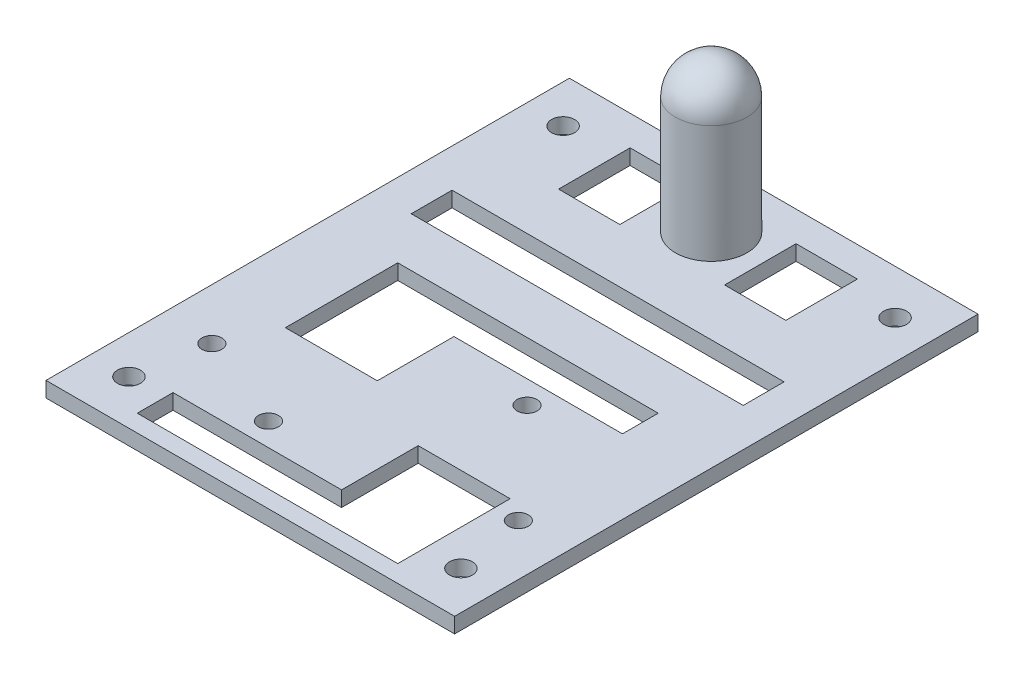
from build123d import *

# Parameters (mm, degrees)
ESQUISSE1_R             = 65
DISQUE_DEPTH            = 3
ESQUISSE3_W             = 30.466369815
ESQUISSE3_H             = 200
COT_S_DEPTH             = 4
D_GAGEMENT_M3_52_D      = 3.9
D_GAGEMENT_M42_D        = 4.5
ESQUISSE15_W            = 89.863216067
ESQUISSE15_H            = 32.096215679
ENL_V_MAT_EXTRU_1_DEPTH = 34
D_GAGEMENT_M3_53_D      = 3.9
D_GAGEMENT_M3_53_DEPTH  = 3
D_GAGEMENT_M3_53_TIP    = 1.171678207
ESQUISSE22_W            = 113.248519978
ESQUISSE22_H            = 34.612898142
ESQUISSE22_W_2          = 51
ESQUISSE22_H_2          = 7
ESQUISSE22_W_3          = 65
ESQUISSE22_H_3          = 8
ENL_V_MAT_EXTRU_3_DEPTH = 10
ESQUISSE23_W            = 12
ESQUISSE23_H            = 14
ENL_V_MAT_EXTRU_4_DEPTH = 10
ESQUISSE24_W            = 18
ESQUISSE24_H            = 15
ENL_V_MAT_EXTRU_5_DEPTH = 10


with BuildPart() as part:
    # Esquisse1 → disque (new body)
    with BuildSketch(Plane(origin=(0, 0, 0), x_dir=(1, 0, 0), z_dir=(0, 1, 0))):
        Circle(ESQUISSE1_R)
    extrude(amount=DISQUE_DEPTH)

    # Esquisse3 → cotés (cut, through all)
    with BuildSketch(Plane(origin=(0, 3, 0), x_dir=(1, 0, 0), z_dir=(0, 1, 0))):
        with Locations((-55.233184908, 0)):
            Rectangle(ESQUISSE3_W, ESQUISSE3_H)
        with Locations((55.233184908, 0)):
            Rectangle(ESQUISSE3_W, ESQUISSE3_H)
    extrude(amount=-COT_S_DEPTH, mode=Mode.SUBTRACT)

    # Dégagement M3.52 (through all)
    with Locations(Plane(origin=(0, 3, 0), x_dir=(1, 0, 0), z_dir=(0, 1, 0))):
        with Locations((-30, -28.76524617)):
            d_gagement_m3_52 = Hole(D_GAGEMENT_M3_52_D / 2)

    # Symétrie1: Dégagement M3.52 across plane
    add(d_gagement_m3_52.mirror(Plane.ZY), mode=Mode.SUBTRACT)

    # Dégagement M42 (through all)
    with Locations(Plane(origin=(0, 3, 0), x_dir=(1, 0, 0), z_dir=(0, 1, 0))):
        with Locations((-32.5, 42.5), (32.5, 42.5), (32.5, -42.5), (-32.5, -42.5)):
            Hole(D_GAGEMENT_M42_D / 2)

    # Esquisse14 → Révolution1 (revolve)
    with BuildSketch(Plane.ZY):
        with BuildLine():
            Line((-35, 3), (-32, 3))
            Line((-32, 3), (-32, 26))
            ThreePointArc((-32, 26), (-34.050252532, 30.949747468), (-39, 33))
            Line((-39, 33), (-39, 30))
            ThreePointArc((-39, 30), (-36.171572875, 28.828427125), (-35, 26))
            Line((-35, 26), (-35, 3))
        make_face()
    revolve(axis=Axis((0, 3, -39), (0, 1, 0)))

    # Esquisse15 → Enlèv. mat.-Extru.1 (cut, through all)
    with BuildSketch(Plane.XZ):
        with Locations((-4.931608034, 67.282861669)):
            Rectangle(ESQUISSE15_W, ESQUISSE15_H)
    extrude(amount=-ENL_V_MAT_EXTRU_1_DEPTH, mode=Mode.SUBTRACT)

    # Dégagement M3.53
    with Locations(Plane(origin=(0, 0, 0), x_dir=(-1, 0, 0), z_dir=(0, -1, 0))):
        with Locations((-11.313708499, -8.367376915), (11.313708499, -36.367376915)):
            Hole(D_GAGEMENT_M3_53_D / 2, depth=D_GAGEMENT_M3_53_DEPTH)
            with Locations((0, 0, -(D_GAGEMENT_M3_53_DEPTH + D_GAGEMENT_M3_53_TIP / 2))):  # 118° drill point
                Cone(0, D_GAGEMENT_M3_53_D / 2, D_GAGEMENT_M3_53_TIP, mode=Mode.SUBTRACT)

    # Esquisse22 → Enlèv. mat.-Extru.3 (cut)
    with BuildSketch(Plane(origin=(0, 0, 0), x_dir=(-1, 0, 0), z_dir=(0, -1, 0))):
        with Locations((16.624259989, 68.541202901)):
            Rectangle(ESQUISSE22_W, ESQUISSE22_H)
        with Locations((0, -0.367376915)):
            Rectangle(ESQUISSE22_W_2, ESQUISSE22_H_2)
        with Locations((0, -44.367376915)):
            Rectangle(ESQUISSE22_W_2, ESQUISSE22_H_2)
        with Locations((0, 16.766315781)):
            Rectangle(ESQUISSE22_W_3, ESQUISSE22_H_3)
    extrude(amount=-ENL_V_MAT_EXTRU_3_DEPTH, mode=Mode.SUBTRACT)

    # Esquisse23 → Enlèv. mat.-Extru.4 (cut)
    with BuildSketch(Plane(origin=(0, 3, 0), x_dir=(1, 0, 0), z_dir=(0, 1, 0))):
        with Locations((-16.25, 38.367376915)):
            Rectangle(ESQUISSE23_W, ESQUISSE23_H)
        with Locations((16.25, 38.367376915)):
            Rectangle(ESQUISSE23_W, ESQUISSE23_H)
    extrude(amount=-ENL_V_MAT_EXTRU_4_DEPTH, mode=Mode.SUBTRACT)

    # Esquisse24 → Enlèv. mat.-Extru.5 (cut)
    with BuildSketch(Plane(origin=(0, 3, 0), x_dir=(1, 0, 0), z_dir=(0, 1, 0))):
        with Locations((-16.5, -11.367376915)):
            Rectangle(ESQUISSE24_W, ESQUISSE24_H)
        with Locations((16.5, -33.367376915)):
            Rectangle(ESQUISSE24_W, ESQUISSE24_H)
    extrude(amount=-ENL_V_MAT_EXTRU_5_DEPTH, mode=Mode.SUBTRACT)


solid = part.part
